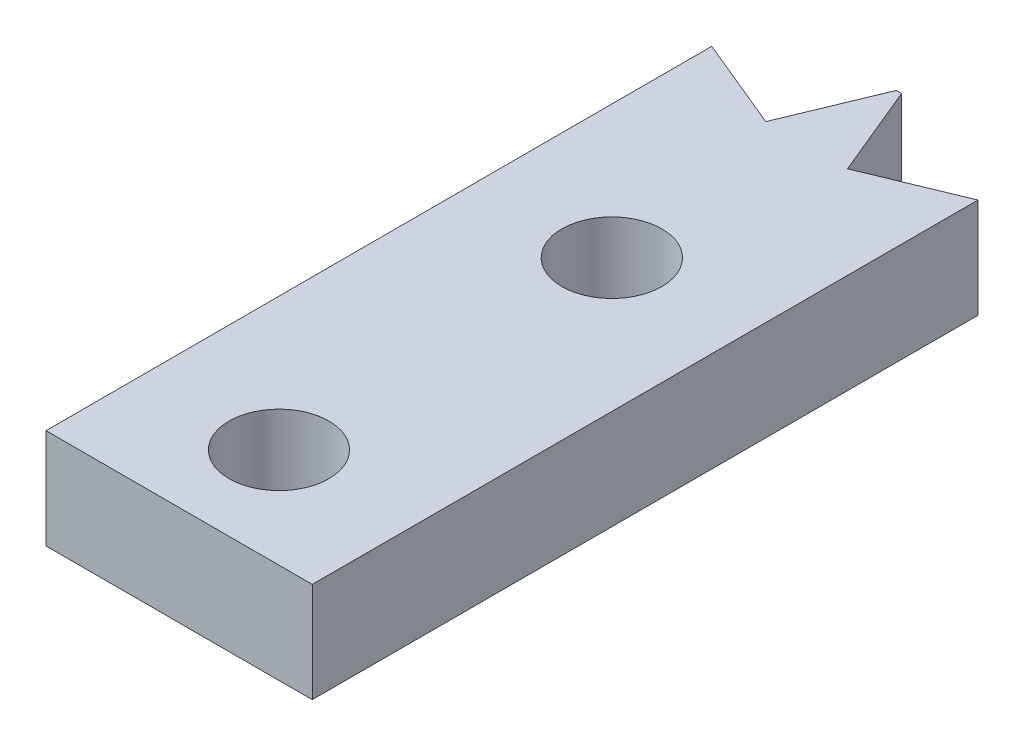
from build123d import *

# Parameters (mm, degrees)
SKETCH1_R           = 1.502144761
SKETCH1_R_2         = 1.500235367
BOSS_EXTRUDE3_DEPTH = 3


with BuildPart() as part:
    # Sketch1 → Boss-Extrude3 (new body)
    with BuildSketch(Plane(origin=(0, 0, 0), x_dir=(1, 0, 0), z_dir=(0, 1, 0))):
        Polygon((-3.272270882, -0.800771607), (-2.124220585, 1.970866991), (-1.964220585, 1.970866991), (-0.816170288, -0.800771607), (1.95546831, 0.34727869), (1.95546831, -17.15272131), (1.95546831, -19.653488119), (-6.043909479, -19.653488119), (-6.043909479, -17.27772131), (-6.043909479, -4.77772131), (-6.043909479, 0.34727869), align=None)
        with Locations((-2.04453169, -6.653488119)):
            Circle(SKETCH1_R, mode=Mode.SUBTRACT)
        with Locations((-2.04453169, -16.653488119)):
            Circle(SKETCH1_R_2, mode=Mode.SUBTRACT)
    extrude(amount=BOSS_EXTRUDE3_DEPTH)


solid = part.part
